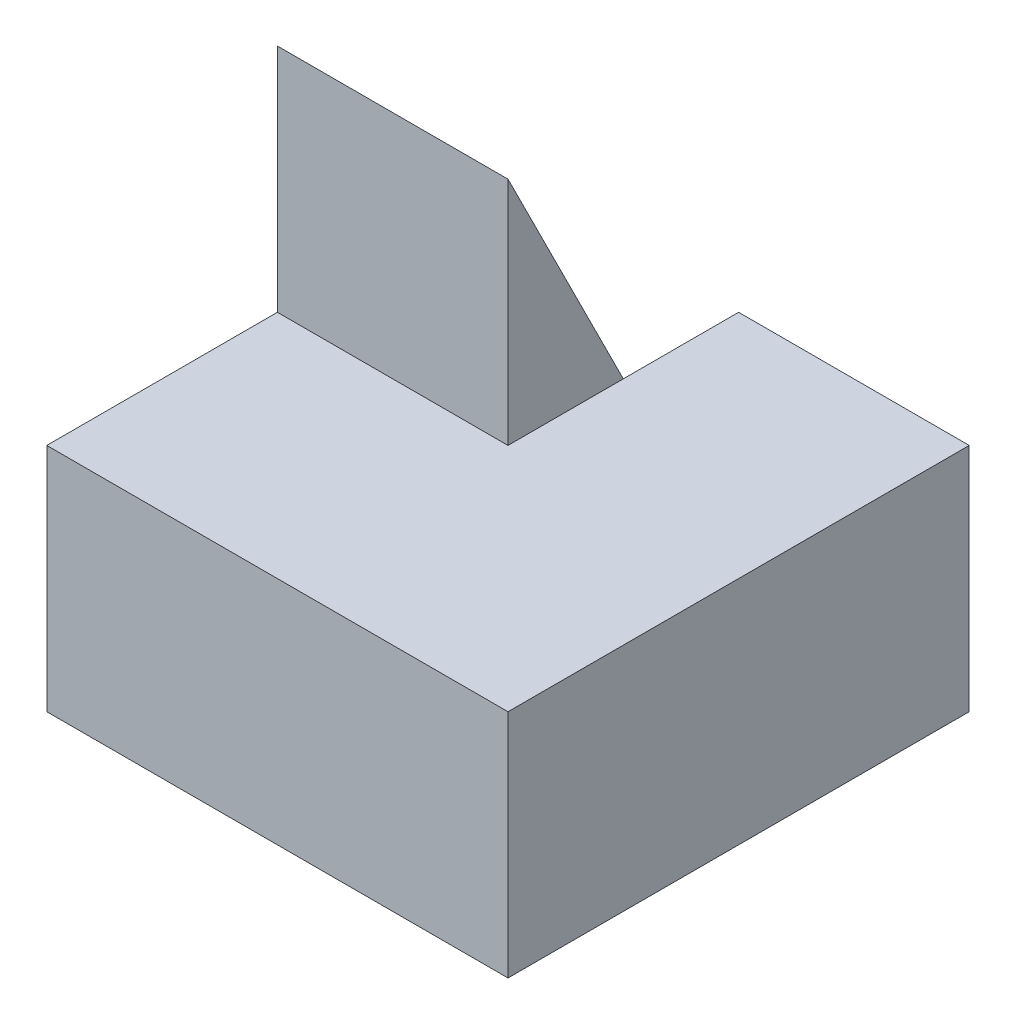
from build123d import *

# Parameters (mm, degrees)
SKETCH1_W           = 4
SKETCH1_H           = 4
BOSS_EXTRUDE1_DEPTH = 4
CUT_EXTRUDE1_DEPTH  = 2
CUT_EXTRUDE2_DEPTH  = 2


with BuildPart() as part:
    # Sketch1 → Boss-Extrude1 (new body)
    with BuildSketch(Plane(origin=(0, 0, 0), x_dir=(1, 0, 0), z_dir=(0, 1, 0))):
        with Locations((2, 2)):
            Rectangle(SKETCH1_W, SKETCH1_H)
    extrude(amount=BOSS_EXTRUDE1_DEPTH)

    # Sketch2 → Cut-Extrude1 (cut)
    with BuildSketch(Plane(origin=(0, 4, 0), x_dir=(1, 0, 0), z_dir=(0, 1, 0))):
        Polygon((4, 4), (2, 4), (2, 2), (0, 2), (0, 0), (4, 0), align=None)
    extrude(amount=-CUT_EXTRUDE1_DEPTH, mode=Mode.SUBTRACT)

    # Sketch3 → Cut-Extrude2 (cut)
    with BuildSketch(Plane.ZY):
        Polygon((-2, 4), (-4, 0), (-4, 4), align=None)
    extrude(amount=-CUT_EXTRUDE2_DEPTH, mode=Mode.SUBTRACT)


solid = part.part
